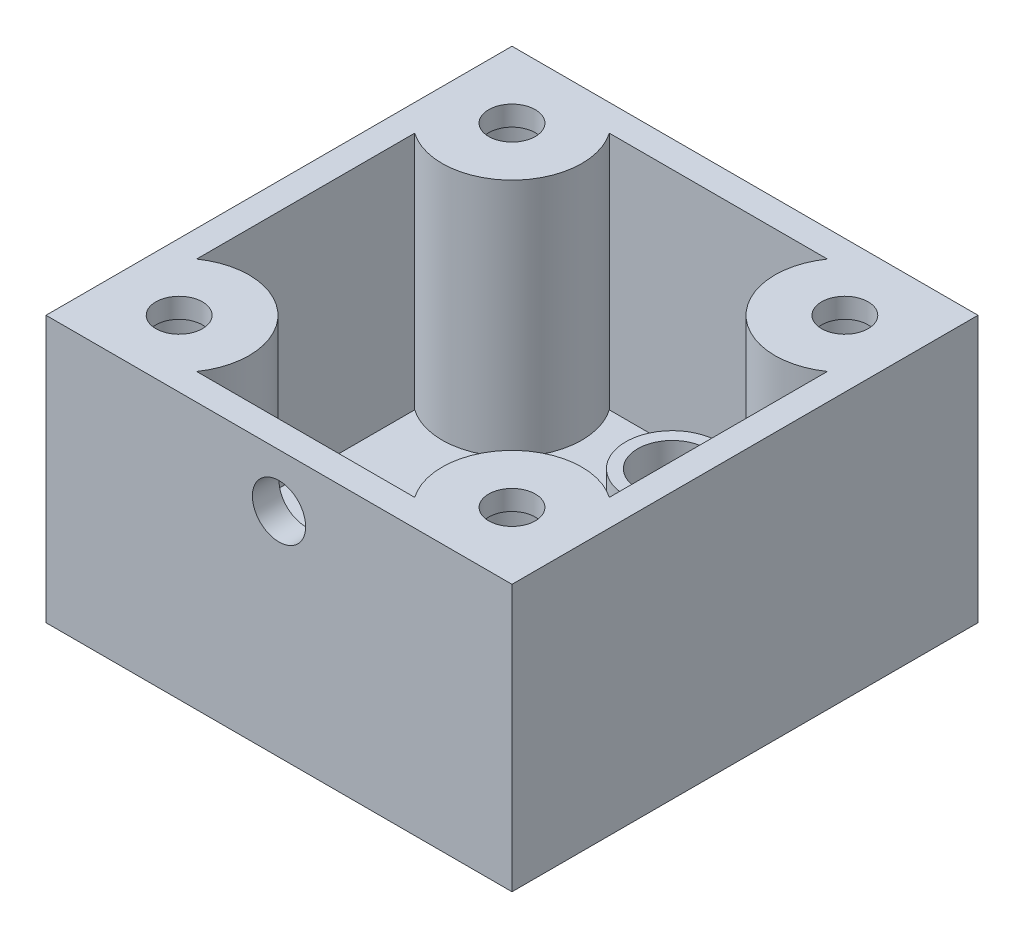
from build123d import *

# Parameters (mm, degrees)
SKETCH2_W           = 35
SKETCH2_H           = 35
BOSS_EXTRUDE1_DEPTH = 20
CUT_EXTRUDE1_START  = -1.5
SKETCH4_R           = 3.25
CUT_EXTRUDE1_DEPTH  = 19.5
CAVITY_DEPTH        = 18
SKETCH10_R          = 3.5
SKETCH10_R_2        = 2.6
BOSS_EXTRUDE4_DEPTH = 2
SKETCH8_R           = 1.75
M3_HOLES_DEPTH      = 21
SKETCH9_R           = 2.6
HOLESS_DEPTH        = 3
CUT_EXTRUDE8_REACH  = 37
SKETCH12_R          = 2


with BuildPart() as part:
    # Sketch2 → Boss-Extrude1 (new body)
    with BuildSketch(Plane(origin=(0, 0, 0), x_dir=(1, 0, 0), z_dir=(0, 1, 0))):
        Rectangle(SKETCH2_W, SKETCH2_H)
    extrude(amount=-BOSS_EXTRUDE1_DEPTH)

    # Sketch4 → Cut-Extrude1 (cut, through all)
    with BuildSketch(Plane(origin=(0, 0, 0), x_dir=(1, 0, 0), z_dir=(0, 1, 0)).offset(CUT_EXTRUDE1_START)):
        with Locations((-12.5, 12.5)):
            Circle(SKETCH4_R)
        with Locations((12.5, 12.5)):
            Circle(SKETCH4_R)
        with Locations((-12.5, -12.5)):
            Circle(SKETCH4_R)
        with Locations((12.5, -12.5)):
            Circle(SKETCH4_R)
    extrude(amount=-CUT_EXTRUDE1_DEPTH, mode=Mode.SUBTRACT)

    # Sketch5 → cavity (cut)
    with BuildSketch(Plane(origin=(0, 0, 0), x_dir=(1, 0, 0), z_dir=(0, 1, 0))):
        with BuildLine():
            Line((-8.191578015, 15.5), (0, 15.5))
            Line((0, 15.5), (8.191578015, 15.5))
            ThreePointArc((8.191578015, 15.5), (8.787689399, 8.787689399), (15.5, 8.191578015))
            Line((15.5, 8.191578015), (15.5, 0))
            Line((15.5, 0), (15.5, -8.191578015))
            ThreePointArc((15.5, -8.191578015), (8.787689399, -8.787689399), (8.191578015, -15.5))
            Line((8.191578015, -15.5), (0, -15.5))
            Line((0, -15.5), (-8.191578015, -15.5))
            ThreePointArc((-8.191578015, -15.5), (-8.787689399, -8.787689399), (-15.5, -8.191578015))
            Line((-15.5, -8.191578015), (-15.5, 0))
            Line((-15.5, 0), (-15.5, 8.191578015))
            ThreePointArc((-15.5, 8.191578015), (-8.787689399, 8.787689399), (-8.191578015, 15.5))
        make_face()
    extrude(amount=-CAVITY_DEPTH, mode=Mode.SUBTRACT)

    # Sketch10 → Boss-Extrude4 (add)
    with BuildSketch(Plane(origin=(0, -18, 0), x_dir=(1, 0, 0), z_dir=(0, 1, 0))):
        with Locations((0, 12.040793939)):
            Circle(SKETCH10_R)
        with Locations((0, 12.040793939)):
            Circle(SKETCH10_R_2, mode=Mode.SUBTRACT)
    extrude(amount=BOSS_EXTRUDE4_DEPTH)

    # Sketch8 (on Top Plane) → M3 holes (cut, through all)
    with BuildSketch(Plane(origin=(0, 0, 0), x_dir=(1, 0, 0), z_dir=(0, 1, 0))):
        with Locations((-12.5, 12.5)):
            Circle(SKETCH8_R)
        with Locations((12.5, 12.5)):
            Circle(SKETCH8_R)
        with Locations((12.5, -12.5)):
            Circle(SKETCH8_R)
        with Locations((-12.5, -12.5)):
            Circle(SKETCH8_R)
    extrude(amount=-M3_HOLES_DEPTH, mode=Mode.SUBTRACT)

    # Sketch9 → holess (cut, through all)
    with BuildSketch(Plane(origin=(0, -18, 0), x_dir=(1, 0, 0), z_dir=(0, 1, 0))):
        with Locations((0, 12.040793939)):
            Circle(SKETCH9_R)
        with BuildLine():
            Line((6.4, -1.921240608), (6.4, -7.078759392))
            ThreePointArc((6.4, -7.078759392), (-6.9, -4.5), (6.4, -1.921240608))
        make_face()
    extrude(amount=-HOLESS_DEPTH, mode=Mode.SUBTRACT)

    # Sketch12 → Cut-Extrude8 (cut, up to next)
    with BuildSketch(Plane.XY.offset(17.5), mode=Mode.PRIVATE) as cut_extrude8_sk1:
        with Locations((0, -4)):
            Circle(SKETCH12_R)
    cut_extrude8_tool1 = extrude(cut_extrude8_sk1.sketch, amount=-CUT_EXTRUDE8_REACH, mode=Mode.PRIVATE) & part.part
    add(cut_extrude8_tool1.solids().sort_by_distance((0, -4, 17.5))[0], mode=Mode.SUBTRACT)


solid = part.part
